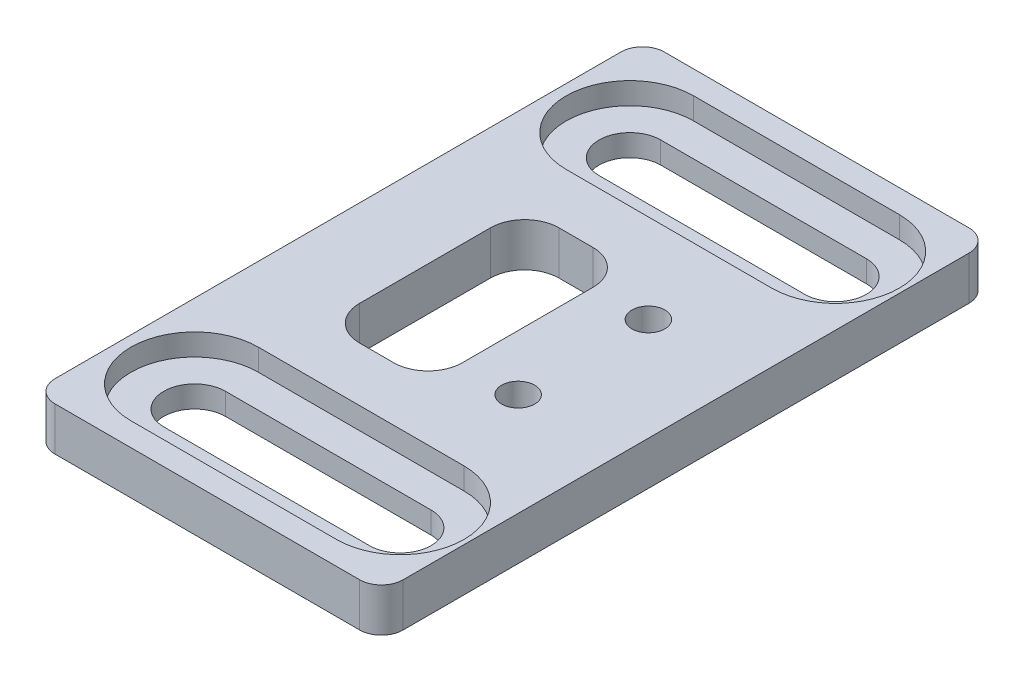
from build123d import *

# Parameters (mm, degrees)
SKETCH1_W           = 25.4
SKETCH1_H           = 44.45
SKETCH1_R           = 1.2
BOSS_EXTRUDE1_DEPTH = 3.175
CUT_EXTRUDE1_DEPTH  = 4.175
FILLET1_R           = 1.5875
CUT_EXTRUDE2_DEPTH  = 1.5875


with BuildPart() as part:
    # Sketch1 → Boss-Extrude1 (new body)
    with BuildSketch(Plane(origin=(0, 0, 0), x_dir=(1, 0, 0), z_dir=(0, 1, 0))):
        with Locations((12.7, 22.225)):
            Rectangle(SKETCH1_W, SKETCH1_H)
        with Locations((17.9, 17.475)):
            Circle(SKETCH1_R, mode=Mode.SUBTRACT)
        with Locations((17.9, 26.975)):
            Circle(SKETCH1_R, mode=Mode.SUBTRACT)
        with BuildLine():
            Line((5.425, 8.6), (20.425, 8.6))
            ThreePointArc((20.425, 8.6), (22.675, 6.35), (20.425, 4.1))
            Line((20.425, 4.1), (5.425, 4.1))
            ThreePointArc((5.425, 4.1), (3.175, 6.35), (5.425, 8.6))
        make_face(mode=Mode.SUBTRACT)
        with BuildLine():
            Line((5.425, 35.85), (20.425, 35.85))
            ThreePointArc((20.425, 35.85), (22.675, 38.1), (20.425, 40.35))
            Line((20.425, 40.35), (5.425, 40.35))
            ThreePointArc((5.425, 40.35), (3.175, 38.1), (5.425, 35.85))
        make_face(mode=Mode.SUBTRACT)
    extrude(amount=BOSS_EXTRUDE1_DEPTH)

    # Sketch2 → Cut-Extrude1 (cut, through all)
    with BuildSketch(Plane(origin=(0, 3.175, 0), x_dir=(1, 0, 0), z_dir=(0, 1, 0))):
        with BuildLine():
            Line((11.35, 14.95), (8.85, 14.95))
            ThreePointArc((8.85, 14.95), (7.082233047, 15.682233047), (6.35, 17.45))
            Line((6.35, 17.45), (6.35, 27))
            ThreePointArc((6.35, 27), (7.082233047, 28.767766953), (8.85, 29.5))
            Line((8.85, 29.5), (11.35, 29.5))
            ThreePointArc((11.35, 29.5), (13.117766953, 28.767766953), (13.85, 27))
            Line((13.85, 27), (13.85, 17.45))
            ThreePointArc((13.85, 17.45), (13.117766953, 15.682233047), (11.35, 14.95))
        make_face()
    extrude(amount=-CUT_EXTRUDE1_DEPTH, mode=Mode.SUBTRACT)

    # Fillet1
    fillet1_edges = [part.edges().sort_by_distance(p)[0] for p in [
        (0, 1.5875, -44.45),
        (25.4, 1.5875, -44.45),
        (25.4, 1.5875, 0),
        (0, 1.5875, 0),
    ]]
    fillet(fillet1_edges, radius=FILLET1_R)

    # Sketch3 → Cut-Extrude2 (cut)
    with BuildSketch(Plane(origin=(0, 3.175, 0), x_dir=(1, 0, 0), z_dir=(0, 1, 0))):
        with BuildLine():
            Line((5.425, 33.45), (20.425, 33.45))
            ThreePointArc((20.425, 33.45), (25.075, 38.1), (20.425, 42.75))
            Line((20.425, 42.75), (5.425, 42.75))
            ThreePointArc((5.425, 42.75), (0.775, 38.1), (5.425, 33.45))
        make_face()
        with BuildLine():
            Line((5.425, 1.7), (20.425, 1.7))
            ThreePointArc((20.425, 1.7), (25.075, 6.35), (20.425, 11))
            Line((20.425, 11), (5.425, 11))
            ThreePointArc((5.425, 11), (0.775, 6.35), (5.425, 1.7))
        make_face()
    extrude(amount=-CUT_EXTRUDE2_DEPTH, mode=Mode.SUBTRACT)


solid = part.part
